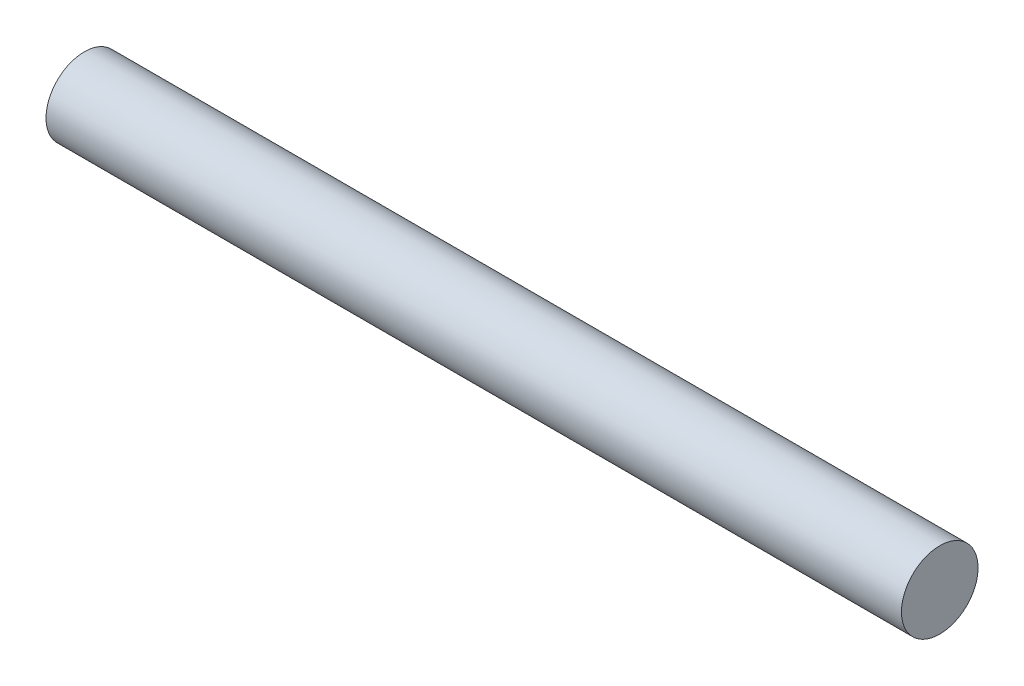
from build123d import *


with BuildPart() as part:
    # ｽｹｯﾁ1 → 回転1 (revolve)
    with BuildSketch(Plane.XY):
        Polygon((0, 0), (0, 3), (29.5, 3), (30.5, 3), (33.5, 3), (33.5, 0), align=None)
    revolve(axis=Axis((0, 0, 0), (1, 0, 0)))

    # ﾐﾗｰ1: part across plane


with BuildPart() as part_1:
    add(part.part)
    add(part.part.mirror(Plane(origin=(0, 0, 0), x_dir=(0, 0, 1), z_dir=(1, 0, 0))))


solid = part_1.part
